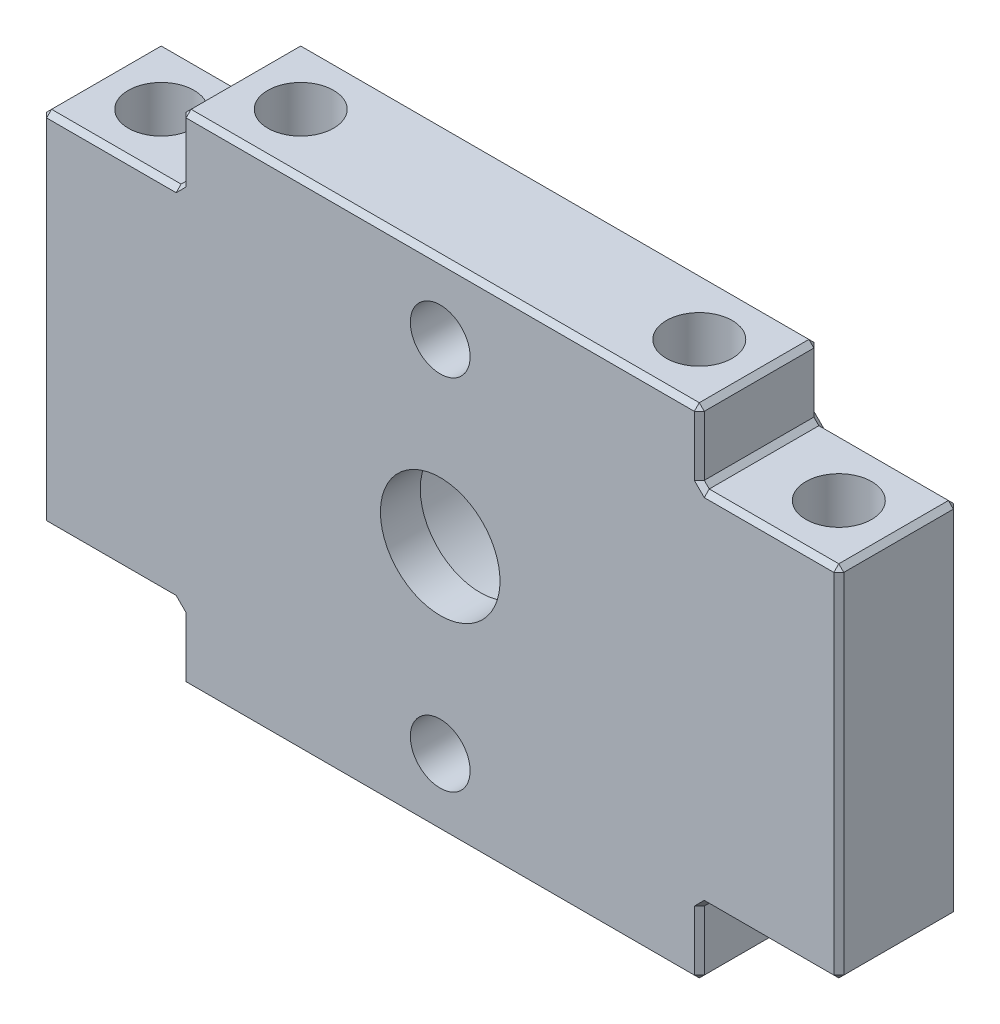
from build123d import *

# Parameters (mm, degrees)
SKETCH1_W                           = 26
SKETCH1_H                           = 6
EXTRUDE1_DEPTH                      = 25
SKETCH2_R                           = 5
CUT_EXTRUDE1_DEPTH                  = 4
SKETCH3_R                           = 3
CUT_EXTRUDE2_DEPTH                  = 12
M4X0_7_TAPPED_HOLE1_D               = 3.3
M4X0_7_TAPPED_HOLE1_DEPTH           = 10.3
M4X0_7_TAPPED_HOLE1_TIP             = 0.991420021
M4X0_7_TAPPED_HOLE1_ON_FACE_2_D     = 3.3
M4X0_7_TAPPED_HOLE1_ON_FACE_2_DEPTH = 10.3
M4X0_7_TAPPED_HOLE1_ON_FACE_2_TIP   = 0.991420021
SKETCH7_R                           = 1.5
CUT_EXTRUDE3_DEPTH                  = 10
CHAMFER2_SIZE                       = 1
SKETCH8_W                           = 7
SKETCH8_H                           = 18
EXTRUDE2_DEPTH                      = 6
M4X0_7_TAPPED_HOLE2_D               = 3.3
M4X0_7_TAPPED_HOLE2_DEPTH           = 8
M4X0_7_TAPPED_HOLE2_TIP             = 0.991420021
M4X0_7_TAPPED_HOLE2_ON_FACE_2_D     = 3.3
M4X0_7_TAPPED_HOLE2_ON_FACE_2_DEPTH = 8
M4X0_7_TAPPED_HOLE2_ON_FACE_2_TIP   = 0.991420021
CHAMFER3_SIZE                       = 0.25


with BuildPart() as part:
    # Sketch1 → Extrude1 (new body)
    with BuildSketch(Plane(origin=(0, 0, 0), x_dir=(1, 0, 0), z_dir=(0, 1, 0))):
        Rectangle(SKETCH1_W, SKETCH1_H)
    extrude(amount=EXTRUDE1_DEPTH)

    # Sketch2 → Cut-Extrude1 (cut)
    with BuildSketch(Plane(origin=(0, 0, -3), x_dir=(-1, 0, 0), z_dir=(0, 0, -1))):
        with Locations((0, 12.5)):
            Circle(SKETCH2_R)
    extrude(amount=-CUT_EXTRUDE1_DEPTH, mode=Mode.SUBTRACT)

    # Sketch3 → Cut-Extrude2 (cut)
    with BuildSketch(Plane(origin=(0, 0, 1), x_dir=(-1, 0, 0), z_dir=(0, 0, -1))):
        with Locations((0, 12.5)):
            Circle(SKETCH3_R)
    extrude(amount=-CUT_EXTRUDE2_DEPTH, mode=Mode.SUBTRACT)

    # M4x0.7 Tapped Hole1
    with Locations(Plane(origin=(10, 25, 0), x_dir=(0, 0, 1), z_dir=(0, 1, 0))):
        with Locations((0, 0), (0, -20)):
            Hole(M4X0_7_TAPPED_HOLE1_D / 2, depth=M4X0_7_TAPPED_HOLE1_DEPTH)
            with Locations((0, 0, -(M4X0_7_TAPPED_HOLE1_DEPTH + M4X0_7_TAPPED_HOLE1_TIP / 2))):  # 118° drill point
                Cone(0, M4X0_7_TAPPED_HOLE1_D / 2, M4X0_7_TAPPED_HOLE1_TIP, mode=Mode.SUBTRACT)

    # M4x0.7 Tapped Hole1 on face 2
    with Locations(Plane(origin=(10, 0, 0), x_dir=(0, 0, -1), z_dir=(0, -1, 0))):
        with Locations((0, 0), (0, -20)):
            Hole(M4X0_7_TAPPED_HOLE1_ON_FACE_2_D / 2, depth=M4X0_7_TAPPED_HOLE1_ON_FACE_2_DEPTH)
            with Locations((0, 0, -(M4X0_7_TAPPED_HOLE1_ON_FACE_2_DEPTH + M4X0_7_TAPPED_HOLE1_ON_FACE_2_TIP / 2))):  # 118° drill point
                Cone(0, M4X0_7_TAPPED_HOLE1_ON_FACE_2_D / 2, M4X0_7_TAPPED_HOLE1_ON_FACE_2_TIP, mode=Mode.SUBTRACT)

    # Sketch7 → Cut-Extrude3 (cut)
    with BuildSketch(Plane.XY.offset(3)):
        with Locations((0, 21.5)):
            Circle(SKETCH7_R)
        with Locations((0, 3.5)):
            Circle(SKETCH7_R)
    extrude(amount=-CUT_EXTRUDE3_DEPTH, mode=Mode.SUBTRACT)

    # Chamfer2
    chamfer2_edges = [part.edges().sort_by_distance(p)[0] for p in [
        (-1.5, 21.5, -3),
        (-1.5, 3.5, -3),
    ]]
    chamfer(chamfer2_edges, length=CHAMFER2_SIZE)

    # Sketch8 → Extrude2 (add)
    with BuildSketch(Plane.XY.offset(3)):
        with Locations((16.5, 12.5)):
            Rectangle(SKETCH8_W, SKETCH8_H)
        with Locations((-16.5, 12.5)):
            Rectangle(SKETCH8_W, SKETCH8_H)
    extrude(amount=-EXTRUDE2_DEPTH)

    # M4x0.7 Tapped Hole2
    with Locations(Plane(origin=(-17, 21.5, 0), x_dir=(0, 0, 1), z_dir=(0, 1, 0))):
        with Locations((0, 0), (0, 34)):
            Hole(M4X0_7_TAPPED_HOLE2_D / 2, depth=M4X0_7_TAPPED_HOLE2_DEPTH)
            with Locations((0, 0, -(M4X0_7_TAPPED_HOLE2_DEPTH + M4X0_7_TAPPED_HOLE2_TIP / 2))):  # 118° drill point
                Cone(0, M4X0_7_TAPPED_HOLE2_D / 2, M4X0_7_TAPPED_HOLE2_TIP, mode=Mode.SUBTRACT)

    # M4x0.7 Tapped Hole2 on face 2
    with Locations(Plane(origin=(17, 3.5, 0), x_dir=(0, 0, -1), z_dir=(0, -1, 0))):
        with Locations((0, 0), (0, -34)):
            Hole(M4X0_7_TAPPED_HOLE2_ON_FACE_2_D / 2, depth=M4X0_7_TAPPED_HOLE2_ON_FACE_2_DEPTH)
            with Locations((0, 0, -(M4X0_7_TAPPED_HOLE2_ON_FACE_2_DEPTH + M4X0_7_TAPPED_HOLE2_ON_FACE_2_TIP / 2))):  # 118° drill point
                Cone(0, M4X0_7_TAPPED_HOLE2_ON_FACE_2_D / 2, M4X0_7_TAPPED_HOLE2_ON_FACE_2_TIP, mode=Mode.SUBTRACT)

    # Chamfer3
    chamfer3_edges = [part.edges().sort_by_distance(p)[0] for p in [
        (13, 25, 0),
        (0, 25, -3),
        (-13, 25, 0),
        (0, 0, -3),
        (13, 0, 0),
        (0, 0, 3),
        (-13, 0, 0),
        (13, 1.75, -3),
        (13, 1.75, 3),
        (13, 3.5, 0),
        (13, 21.5, 0),
        (20, 21.5, 0),
        (20, 3.5, 0),
        (16.5, 3.5, 3),
        (20, 12.5, 3),
        (16.5, 21.5, 3),
        (16.5, 21.5, -3),
        (20, 12.5, -3),
        (16.5, 3.5, -3),
        (-13, 1.75, 3),
        (-13, 1.75, -3),
        (0, 25, 3),
        (-13, 23.25, -3),
        (13, 23.25, -3),
        (-13, 21.5, 0),
        (-13, 3.5, 0),
        (-20, 3.5, 0),
        (-20, 21.5, 0),
        (13, 23.25, 3),
        (-16.5, 21.5, 3),
        (-20, 12.5, 3),
        (-16.5, 3.5, 3),
        (-13, 23.25, 3),
        (-16.5, 3.5, -3),
        (-20, 12.5, -3),
        (-16.5, 21.5, -3),
    ]]
    chamfer(chamfer3_edges, length=CHAMFER3_SIZE)


solid = part.part
